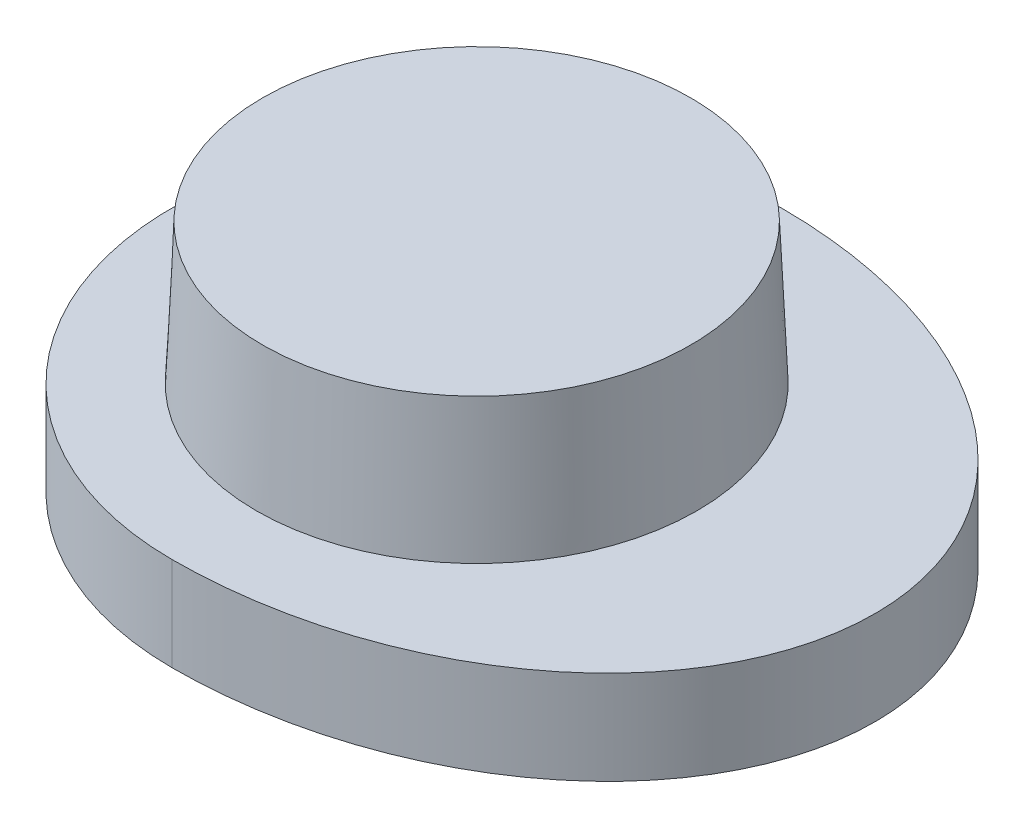
from build123d import *

# Parameters (mm, degrees)
BOSS_EXTRUDE4_DEPTH = 2.000034
SCALE1_SCALE        = 0.510872955


with BuildPart() as part:
    # Sketch1 one side (on Front Plane) → Revolve25 (revolve)
    with BuildSketch(Plane.XY):
        with BuildLine():
            Line((-4.526114828, -19.925267112), (-4.682614804, -1.992146118))
            Line((-4.682614804, -1.992146118), (-4.7, 0))
            Line((-4.7, 0), (-6.5, 0))
            Line((-6.5, 0), (-6.5, -2))
            Line((-6.5, -2), (-5.582580535, -2))
            Line((-5.582580535, -2), (-5.425496915, -20))
            Line((-5.425496915, -20), (-2.794168337, -36.613554791))
            ThreePointArc((-2.794168337, -36.613554791), (-1.837287228, -38.322188957), (0, -39))
            Line((0, -39), (0, -38.1))
            ThreePointArc((0, -38.1), (-1.252783984, -37.637823588), (-1.905248831, -36.472763773))
            Line((-1.905248831, -36.472763773), (-4.526114828, -19.925267112))
        make_face()
    revolve(axis=Axis((0, 0, 0), (0, -1, 0)))


with BuildPart() as body_2:
    # Sketch1_10 one side → Revolve31 (revolve)
    with BuildSketch(Plane.XY):
        Polygon((26.569018636, 2.999966443), (22, 2.999966443), (22, 1.999966443), (26, 1.999966443), (26, -2.000033557), (28.5, -2.000033557), (28.5, 0), (26.7, 0), align=None)
    revolve(axis=Axis((22, 17.95552364, 0), (0, -1, 0)))

    # Sketch2 → Boss-Extrude4 (add)
    with BuildSketch(Plane(origin=(0, -2.000033557, 0), x_dir=(-1, 0, 0), z_dir=(0, -1, 0))):
        with BuildLine():
            Line((-22, 4), (-22, 6.5))
            add(Edge.make_bspline(
                [(-22, 6.5), (-30.5, 6.5), (-30.5, 0), (-30.5, -6.5), (-22, -6.5)],
                knots=[1.570796327, 1.570796327, 1.570796327, 3.141592654, 3.141592654, 4.71238898, 4.71238898, 4.71238898], degree=2, weights=[1, 0.707106781, 1, 0.707106781, 1]))
            Line((-22, -6.5), (-22, -4))
            ThreePointArc((-22, -4), (-26, 0), (-22, 4))
        make_face()
    extrude(amount=-BOSS_EXTRUDE4_DEPTH)


with BuildPart() as body_2_1:
    # Scale1: scaled about (22.846218841, -0.018057413, 0)
    add(body_2.part.scale(SCALE1_SCALE).moved(Location((11.174703513, -0.008832369, 0))))


solid = body_2_1.part
